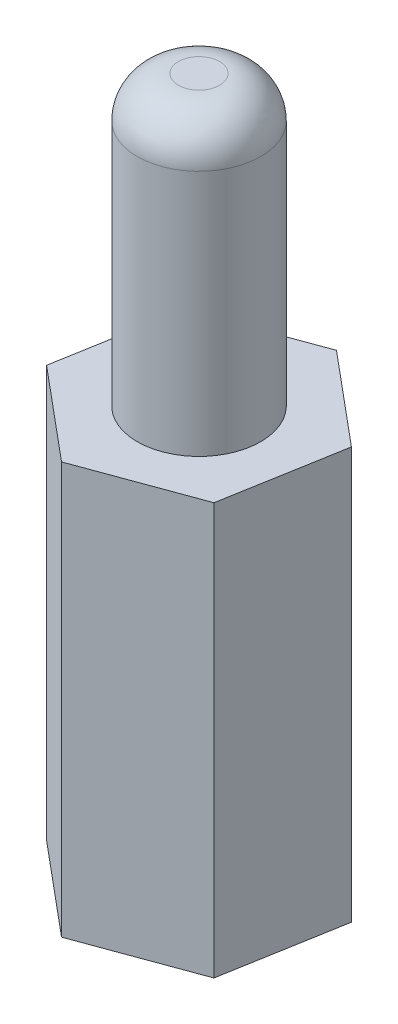
from build123d import *

# Parameters (mm, degrees)
BOSS_EXTRUDE1_DEPTH = 10
SKETCH2_R           = 1.5
BOSS_EXTRUDE2_DEPTH = 7
SKETCH3_R           = 1.5
CUT_EXTRUDE1_DEPTH  = 7
FILLET1_R           = 1


with BuildPart() as part:
    # Sketch1 → Boss-Extrude1 (new body)
    with BuildSketch(Plane(origin=(0, 0, 0), x_dir=(1, 0, 0), z_dir=(0, 1, 0))):
        Polygon((2.214824591, -1.851454932), (2.7108193, 0.992366895), (0.495994709, 2.843821827), (-2.214824591, 1.851454932), (-2.7108193, -0.992366895), (-0.495994709, -2.843821827), align=None)
    extrude(amount=BOSS_EXTRUDE1_DEPTH)

    # Sketch2 → Boss-Extrude2 (add)
    with BuildSketch(Plane(origin=(0, 10, 0), x_dir=(1, 0, 0), z_dir=(0, 1, 0))):
        Circle(SKETCH2_R)
    extrude(amount=BOSS_EXTRUDE2_DEPTH)

    # Sketch3 → Cut-Extrude1 (cut)
    with BuildSketch(Plane.XZ):
        Circle(SKETCH3_R)
    extrude(amount=-CUT_EXTRUDE1_DEPTH, mode=Mode.SUBTRACT)

    # Fillet1
    fillet1_edges = [part.edges().sort_by_distance(p)[0] for p in [
        (-1.5, 17, 0),
    ]]
    fillet(fillet1_edges, radius=FILLET1_R)


solid = part.part
